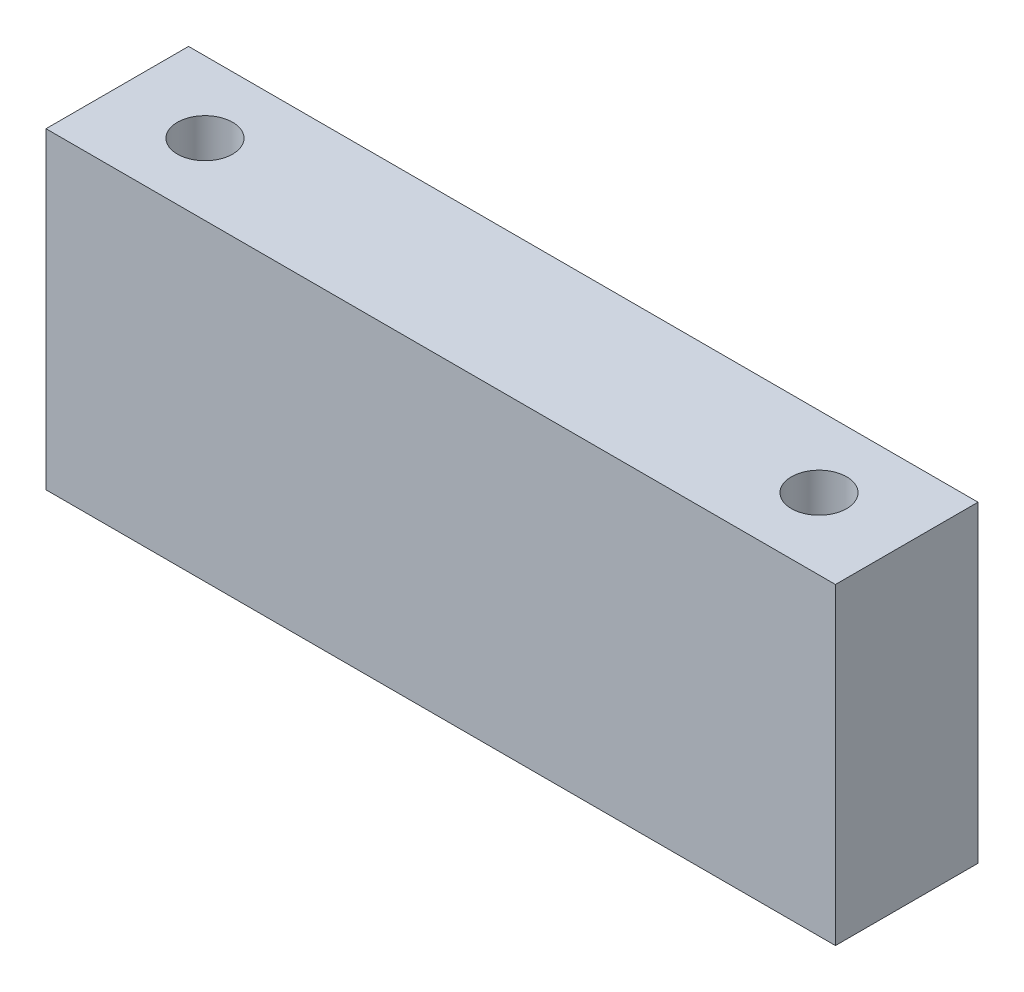
from build123d import *

# Parameters (mm, degrees)
SKETCH1_W           = 57.15
SKETCH1_H           = 10.32
SKETCH1_R           = 2
BOSS_EXTRUDE1_DEPTH = 22.64


with BuildPart() as part:
    # Sketch1 → Boss-Extrude1 (new body)
    with BuildSketch(Plane(origin=(0, 0, 0), x_dir=(1, 0, 0), z_dir=(0, 1, 0))):
        Rectangle(SKETCH1_W, SKETCH1_H)
        with Locations((-22.225, 0)):
            Circle(SKETCH1_R, mode=Mode.SUBTRACT)
        with Locations((22.225, 0)):
            Circle(SKETCH1_R, mode=Mode.SUBTRACT)
    extrude(amount=BOSS_EXTRUDE1_DEPTH)


solid = part.part
